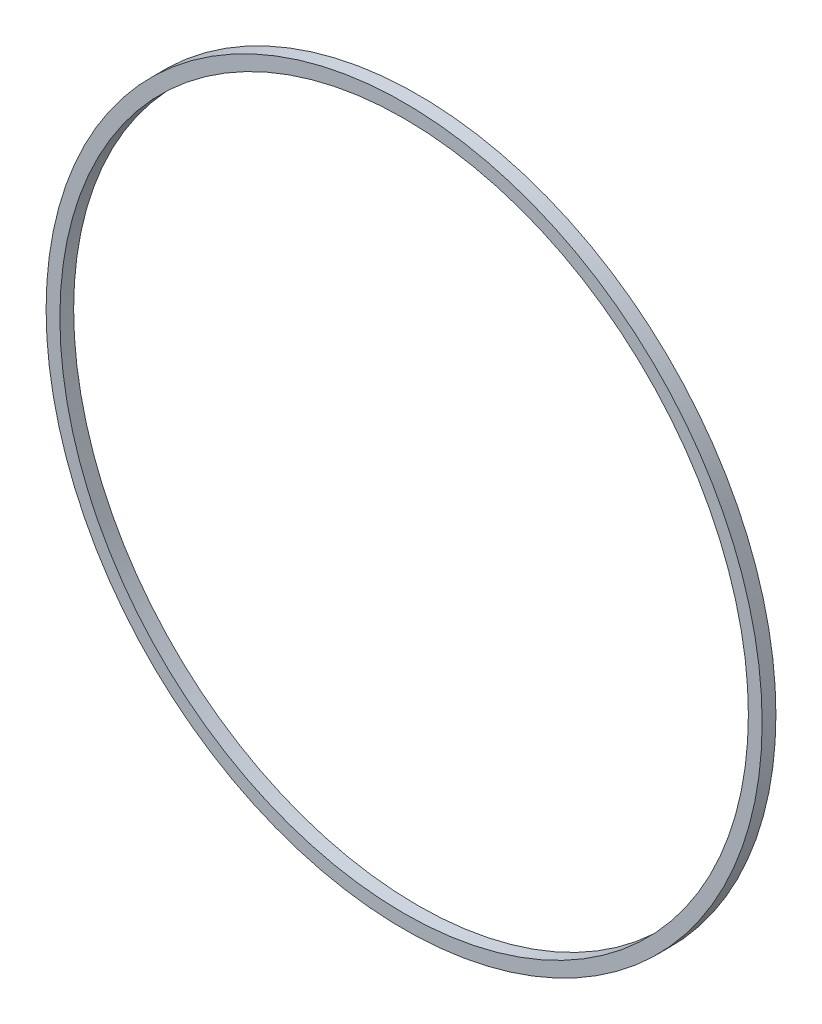
from build123d import *

# Parameters (mm, degrees)
SKETCH1_R           = 66.04
SKETCH1_R_2         = 63.5
BOSS_EXTRUDE1_DEPTH = 2.54


with BuildPart() as part:
    # Sketch1 → Boss-Extrude1 (new body)
    with BuildSketch(Plane.XY):
        Circle(SKETCH1_R)
        Circle(SKETCH1_R_2, mode=Mode.SUBTRACT)
    extrude(amount=BOSS_EXTRUDE1_DEPTH)


solid = part.part
